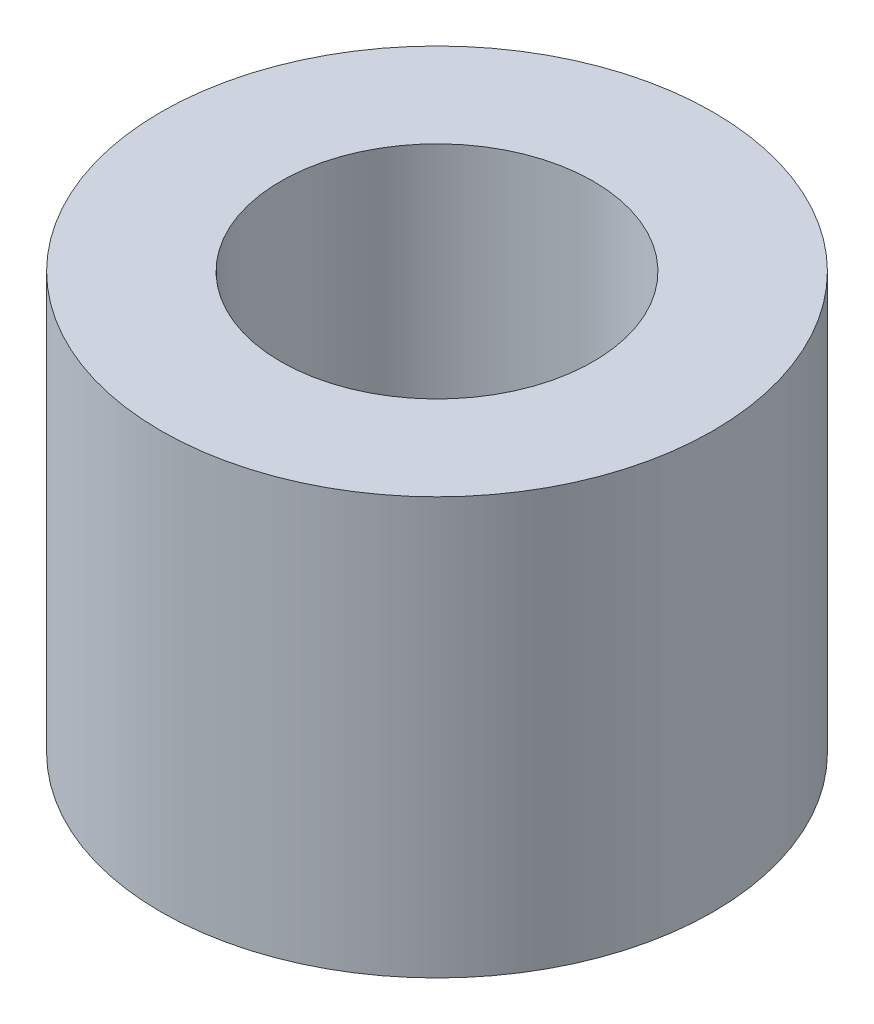
from build123d import *

# Parameters (mm, degrees)
SKETCH1_R           = 2.65
SKETCH1_R_2         = 1.5
BOSS_EXTRUDE1_DEPTH = 4


with BuildPart() as part:
    # Sketch1 → Boss-Extrude1 (new body)
    with BuildSketch(Plane(origin=(0, 0, 0), x_dir=(1, 0, 0), z_dir=(0, 1, 0))):
        Circle(SKETCH1_R)
        Circle(SKETCH1_R_2, mode=Mode.SUBTRACT)
    extrude(amount=BOSS_EXTRUDE1_DEPTH)


solid = part.part
